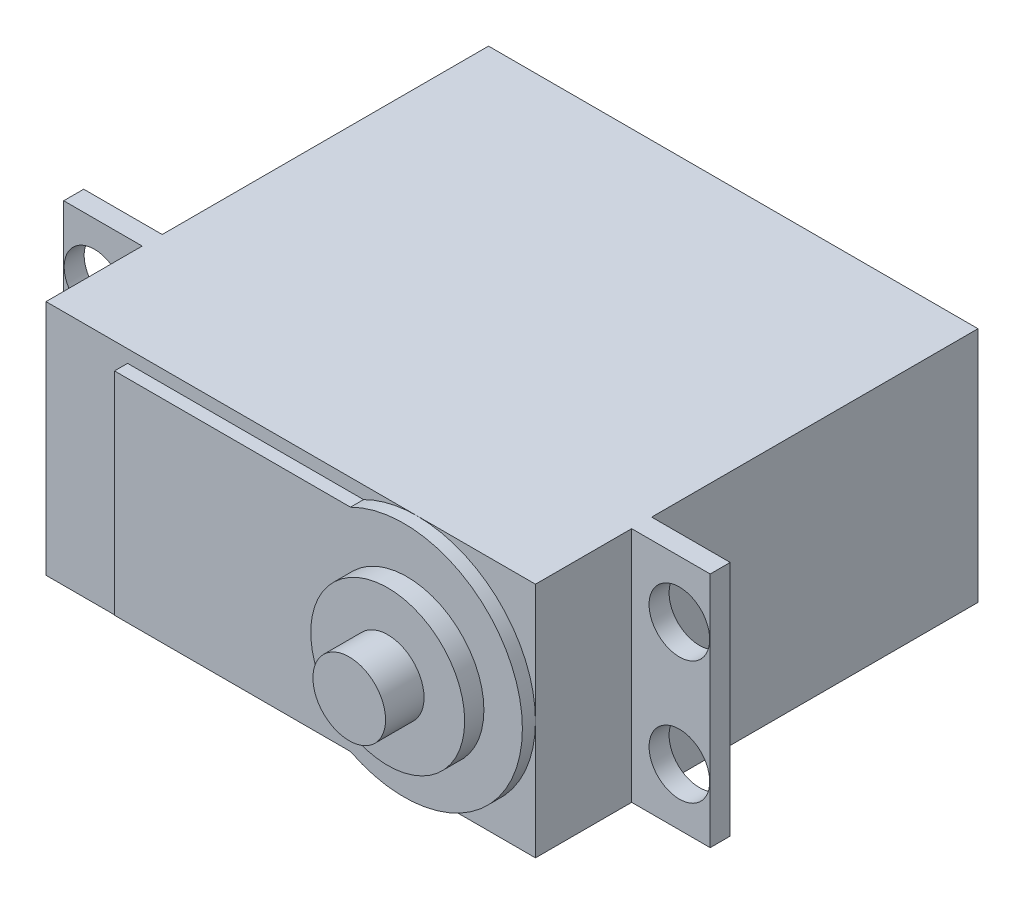
from build123d import *

# Parameters (mm, degrees)
SKETCH3_W           = 40.386
SKETCH3_H           = 19.558
BOSS_EXTRUDE2_DEPTH = 26.924
SKETCH4_W           = 53.34
SKETCH4_H           = 19.558
BOSS_EXTRUDE3_DEPTH = 1.651
SKETCH5_R           = 2.5019
CUT_EXTRUDE1_DEPTH  = 3.175
SKETCH6_W           = 40.386
SKETCH6_H           = 19.558
BOSS_EXTRUDE4_DEPTH = 7.9375
BOSS_EXTRUDE5_DEPTH = 1.0795
SKETCH8_R           = 6.35
BOSS_EXTRUDE6_DEPTH = 1.5875
SKETCH10_R          = 2.9972
BOSS_EXTRUDE7_DEPTH = 3.175


with BuildPart() as part:
    # Sketch3 → Boss-Extrude2 (new body)
    with BuildSketch(Plane.XY):
        with Locations((-53.574618647, -12.967080077)):
            Rectangle(SKETCH3_W, SKETCH3_H)
    extrude(amount=BOSS_EXTRUDE2_DEPTH)

    # Sketch4 → Boss-Extrude3 (add)
    with BuildSketch(Plane.XY.offset(26.924)):
        with Locations((-53.574618647, -12.967080077)):
            Rectangle(SKETCH4_W, SKETCH4_H)
    extrude(amount=BOSS_EXTRUDE3_DEPTH)

    # Sketch5 → Cut-Extrude1 (cut)
    with BuildSketch(Plane.XY.offset(28.575)):
        with Locations((-77.704618647, -7.887080077)):
            Circle(SKETCH5_R)
        with Locations((-29.444618647, -7.887080077)):
            Circle(SKETCH5_R)
        with Locations((-29.444618647, -18.047080077)):
            Circle(SKETCH5_R)
        with Locations((-77.704618647, -18.047080077)):
            Circle(SKETCH5_R)
    extrude(amount=-CUT_EXTRUDE1_DEPTH, mode=Mode.SUBTRACT)

    # Sketch6 → Boss-Extrude4 (add)
    with BuildSketch(Plane.XY.offset(28.575)):
        with Locations((-53.574618647, -12.967080077)):
            Rectangle(SKETCH6_W, SKETCH6_H)
    extrude(amount=BOSS_EXTRUDE4_DEPTH)

    # Sketch7 → Boss-Extrude5 (add)
    with BuildSketch(Plane.XY.offset(36.5125)):
        with BuildLine():
            Line((-67.036618647, -21.698330077), (-67.036618647, -4.235830077))
            Line((-67.036618647, -4.235830077), (-47.564493582, -4.235830077))
            ThreePointArc((-47.564493582, -4.235830077), (-33.381618647, -12.967080077), (-47.564493582, -21.698330077))
            Line((-47.564493582, -21.698330077), (-67.036618647, -21.698330077))
        make_face()
    extrude(amount=BOSS_EXTRUDE5_DEPTH)

    # Sketch8 → Boss-Extrude6 (add)
    with BuildSketch(Plane.XY.offset(37.592)):
        with Locations((-42.906618647, -13.221080077)):
            Circle(SKETCH8_R)
    extrude(amount=BOSS_EXTRUDE6_DEPTH)

    # Sketch10 → Boss-Extrude7 (add)
    with BuildSketch(Plane.XY.offset(39.1795)):
        with Locations((-42.906618647, -13.221080077)):
            Circle(SKETCH10_R)
    extrude(amount=BOSS_EXTRUDE7_DEPTH)


solid = part.part
